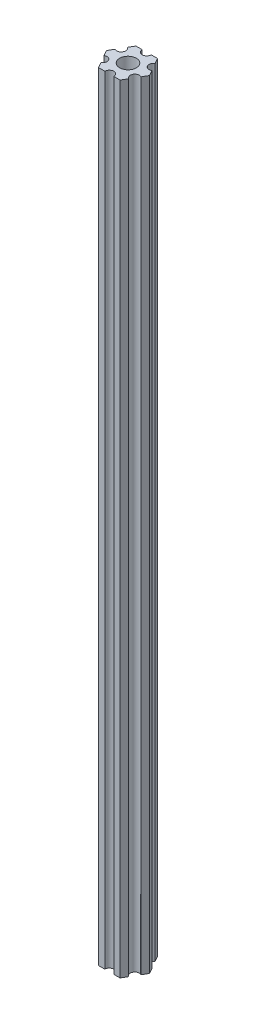
from build123d import *

# Parameters (mm, degrees)
ESBO_O1_R                = 2.79
RESSALTO_EXTRUS_O1_DEPTH = 260


with BuildPart() as part:
    # Esboço1 → Ressalto-extrusão1 (new body)
    with BuildSketch(Plane(origin=(0, 85, 0), x_dir=(1, 0, 0), z_dir=(0, 1, 0))):
        with BuildLine():
            Line((6.162658774, -1.825961894), (7.216878365, 0))
            Line((7.216878365, 0), (6.162658774, 1.825961894))
            ThreePointArc((6.162658774, 1.825961894), (4.113620668, 2.375), (4.662658774, 4.424038106))
            Line((4.662658774, 4.424038106), (3.608439182, 6.25))
            Line((3.608439182, 6.25), (1.5, 6.25))
            ThreePointArc((1.5, 6.25), (0, 4.75), (-1.5, 6.25))
            Line((-1.5, 6.25), (-3.608439182, 6.25))
            Line((-3.608439182, 6.25), (-4.662658774, 4.424038106))
            ThreePointArc((-4.662658774, 4.424038106), (-4.113620668, 2.375), (-6.162658774, 1.825961894))
            Line((-6.162658774, 1.825961894), (-7.216878365, 0))
            Line((-7.216878365, 0), (-6.162658774, -1.825961894))
            ThreePointArc((-6.162658774, -1.825961894), (-4.113620668, -2.375), (-4.662658774, -4.424038106))
            Line((-4.662658774, -4.424038106), (-3.608439182, -6.25))
            Line((-3.608439182, -6.25), (-1.5, -6.25))
            ThreePointArc((-1.5, -6.25), (0, -4.75), (1.5, -6.25))
            Line((1.5, -6.25), (3.608439182, -6.25))
            Line((3.608439182, -6.25), (4.662658774, -4.424038106))
            ThreePointArc((4.662658774, -4.424038106), (4.113620668, -2.375), (6.162658774, -1.825961894))
        make_face()
        Circle(ESBO_O1_R, mode=Mode.SUBTRACT)
    extrude(amount=-RESSALTO_EXTRUS_O1_DEPTH)


solid = part.part
